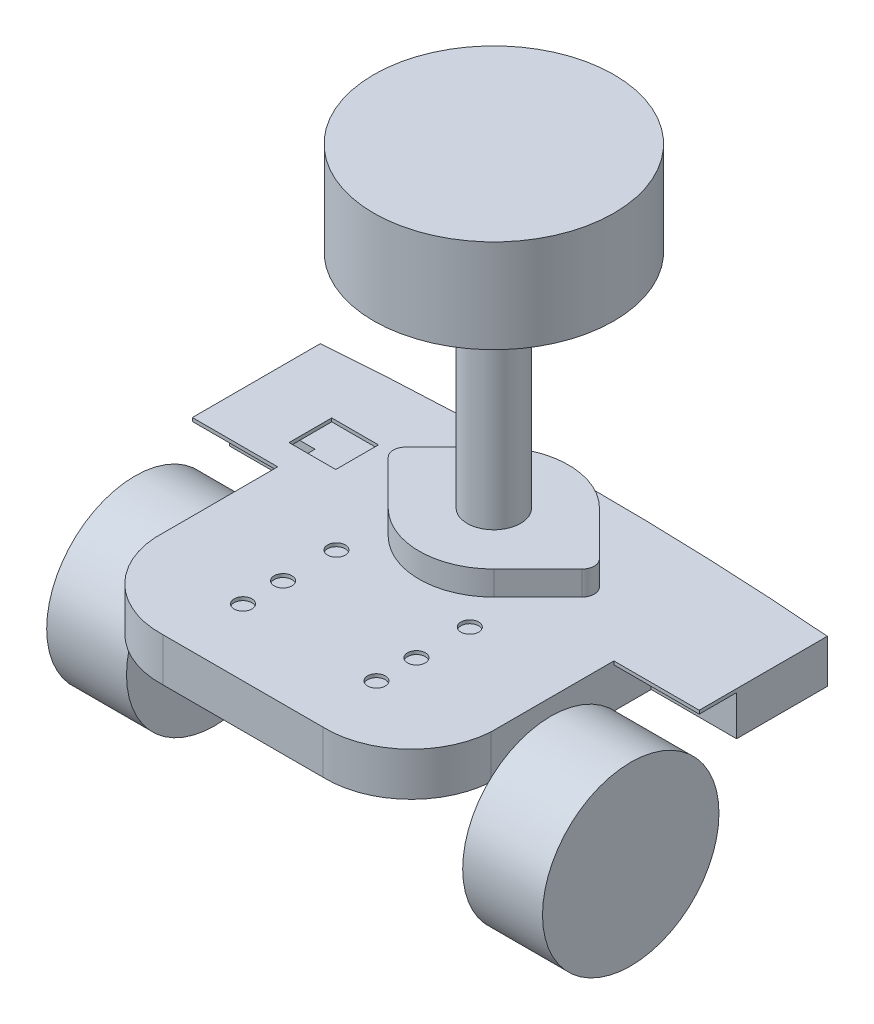
from build123d import *

# Parameters (mm, degrees)
EXTRUDE1_DEPTH     = 0.8128
SKETCH3_R          = 17.78
SKETCH3_R_2        = 1.651
EXTRUDE2_DEPTH     = 1.8128
SKETCH4_W          = 11.1125
SKETCH4_H          = 10.16
CUT_EXTRUDE1_DEPTH = 1.8128
SKETCH5_R          = 2.1082
EXTRUDE3_DEPTH     = 1.8128
EXTRUDE5_DEPTH     = 0.8128
EXTRUDE6_DEPTH     = 9.525
SKETCH8_R          = 2.918849546
SKETCH8_R_2        = 17.78
EXTRUDE7_DEPTH     = 6.604
SKETCH9_R          = 21
EXTRUDE8_DEPTH     = 19
SKETCH10_R         = 6.35
EXTRUDE9_DEPTH     = 52.832
SKETCH11_R         = 28.575
EXTRUDE10_DEPTH    = 22.225


with BuildPart() as part:
    # Sketch1 → Extrude1 (new body)
    with BuildSketch(Plane(origin=(0, 0, 0), x_dir=(1, 0, 0), z_dir=(0, 1, 0))):
        with BuildLine():
            Line((19.05, 0), (-19.05, 0))
            ThreePointArc((-19.05, 0), (-33.392740352, 5.273235613), (-40.005, 19.05))
            Line((-40.005, 19.05), (-40.005, 48.26))
            Line((-40.005, 48.26), (-60.325, 48.26))
            Line((-60.325, 48.26), (-60.325, 78.74))
            Line((-60.325, 78.74), (60.325, 78.74))
            Line((60.325, 78.74), (60.325, 48.26))
            Line((60.325, 48.26), (40.005, 48.26))
            Line((40.005, 48.26), (40.005, 19.05))
            ThreePointArc((40.005, 19.05), (33.392740352, 5.273235613), (19.05, 0))
        make_face()
    extrude(amount=EXTRUDE1_DEPTH)

    # Sketch3 → Extrude2 (cut, through all)
    with BuildSketch(Plane(origin=(0, 0.8128, 0), x_dir=(-1, 0, 0), z_dir=(0, 1, 0))):
        with Locations(Location((0, -59.69, 0), (0, 0, 90))):  # turned: the seam where the file's is
            Circle(SKETCH3_R)
        with Locations(Location((21, -59.69, 0), (0, 0, 90))):  # turned: the seam where the file's is
            Circle(SKETCH3_R_2)
        with Locations(Location((-21, -59.69, 0), (0, 0, 270))):  # turned: the seam where the file's is
            Circle(SKETCH3_R_2)
    extrude(amount=-EXTRUDE2_DEPTH, mode=Mode.SUBTRACT)

    # Sketch4 → Cut-Extrude1 (cut, through all)
    with BuildSketch(Plane(origin=(0, 0.8128, 0), x_dir=(-1, 0, 0), z_dir=(0, 1, 0))):
        with Locations((38.1, -59.69)):
            Rectangle(SKETCH4_W, SKETCH4_H)
    extrude(amount=-CUT_EXTRUDE1_DEPTH, mode=Mode.SUBTRACT)

    # Sketch5 → Extrude3 (cut, through all)
    with BuildSketch(Plane(origin=(0, 0.8128, 0), x_dir=(-1, 0, 0), z_dir=(0, 1, 0))):
        with Locations(Location((15.875, -38.1, 0), (0, 0, 90))):  # turned: the seam where the file's is
            Circle(SKETCH5_R)
        with Locations(Location((15.875, -25.4, 0), (0, 0, 90))):  # turned: the seam where the file's is
            Circle(SKETCH5_R)
        with Locations(Location((15.875, -15.875, 0), (0, 0, 90))):  # turned: the seam where the file's is
            Circle(SKETCH5_R)
        with Locations(Location((-15.875, -15.875, 0), (0, 0, 270))):  # turned: the seam where the file's is
            Circle(SKETCH5_R)
        with Locations(Location((-15.875, -25.4, 0), (0, 0, 270))):  # turned: the seam where the file's is
            Circle(SKETCH5_R)
        with Locations(Location((-15.875, -38.1, 0), (0, 0, 270))):  # turned: the seam where the file's is
            Circle(SKETCH5_R)
    extrude(amount=-EXTRUDE3_DEPTH, mode=Mode.SUBTRACT)

    # Sketch6 → Extrude5 (add, through all)
    with BuildSketch(Plane(origin=(0, 0.8128, 0), x_dir=(1, 0, 0), z_dir=(0, 1, 0))):
        with BuildLine():
            Line((-60.325, 78.74), (60.325, 78.74))
            ThreePointArc((60.325, 78.74), (0, 81.131617756), (-60.325, 78.74))
        make_face()
    extrude(amount=-EXTRUDE5_DEPTH)

    # Sketch7 → Extrude6 (add)
    with BuildSketch(Plane.XZ):
        with BuildLine():
            Line((-60.325, -78.74), (-60.325, -57.15))
            Line((-60.325, -57.15), (-40.005, -57.15))
            Line((-40.005, -57.15), (-40.005, -19.05))
            ThreePointArc((-40.005, -19.05), (-33.392740352, -5.273235613), (-19.05, 0))
            Line((-19.05, 0), (19.05, 0))
            ThreePointArc((19.05, 0), (33.392740352, -5.273235613), (40.005, -19.05))
            Line((40.005, -19.05), (40.005, -57.15))
            Line((40.005, -57.15), (60.325, -57.15))
            Line((60.325, -57.15), (60.325, -78.74))
            ThreePointArc((60.325, -78.74), (0, -81.131617756), (-60.325, -78.74))
        make_face()
    extrude(amount=EXTRUDE6_DEPTH)

    # Sketch8 → Extrude7 (add)
    with BuildSketch(Plane(origin=(0, 0, 0), x_dir=(1, 0, 0), z_dir=(0, 1, 0))):
        with BuildLine():
            Line((-12.582440718, 72.252268329), (-23.065593441, 61.752281845))
            ThreePointArc((-23.065593441, 61.752281845), (-19.884086429, 62.387113192), (-18.081150454, 59.69))
            ThreePointArc((-18.081150454, 59.69), (-19.884086429, 56.992886808), (-23.065593441, 57.627718155))
            Line((-23.065593441, 57.627718155), (-12.582440718, 47.127731671))
            ThreePointArc((-12.582440718, 47.127731671), (-17.78, 59.69), (-12.582440718, 72.252268329))
        make_face()
        with Locations((-21, 59.69)):
            Circle(SKETCH8_R)
        with Locations((0, 59.69)):
            Circle(SKETCH8_R_2)
        with BuildLine():
            Line((23.065593441, 61.752281845), (12.582440718, 72.252268329))
            ThreePointArc((12.582440718, 72.252268329), (16.429306071, 66.487521755), (17.78, 59.69))
            ThreePointArc((17.78, 59.69), (16.429306071, 52.892478245), (12.582440718, 47.127731671))
            Line((12.582440718, 47.127731671), (23.065593441, 57.627718155))
            ThreePointArc((23.065593441, 57.627718155), (18.081150454, 59.69), (23.065593441, 61.752281845))
        make_face()
        with Locations((21, 59.69)):
            Circle(SKETCH8_R)
    extrude(amount=EXTRUDE7_DEPTH)

    # Sketch10 → Extrude9 (add)
    with BuildSketch(Plane(origin=(0, 6.604, 0), x_dir=(-1, 0, 0), z_dir=(0, 1, 0))):
        with Locations(Location((0, -59.69, 0), (0, 0, 90))):  # turned: the seam where the file's is
            Circle(SKETCH10_R)
    extrude(amount=EXTRUDE9_DEPTH)


with BuildPart() as body_2:
    # Sketch9 → Extrude8 (new body)
    with BuildSketch(Plane(origin=(40.005, 0, 0), x_dir=(0, 0, -1), z_dir=(1, 0, 0))):
        with Locations((33.274, -24.0792)):
            Circle(SKETCH9_R)
    extrude(amount=EXTRUDE8_DEPTH)


with BuildPart() as body_3:
    # Mirror3: mirrored copy
    add(body_2.part.mirror(Plane(origin=(0, 0, 0), x_dir=(0, 0, 1), z_dir=(1, 0, 0))))


with BuildPart() as body_4:
    # Sketch11 → Extrude10 (new body)
    with BuildSketch(Plane(origin=(0, 59.436, 0), x_dir=(-1, 0, 0), z_dir=(0, 1, 0))):
        with Locations(Location((0, -59.69, 0), (0, 0, 90))):  # turned: the seam where the file's is
            Circle(SKETCH11_R)
    extrude(amount=EXTRUDE10_DEPTH)


solid = Compound([part.part, body_2.part, body_3.part, body_4.part])
